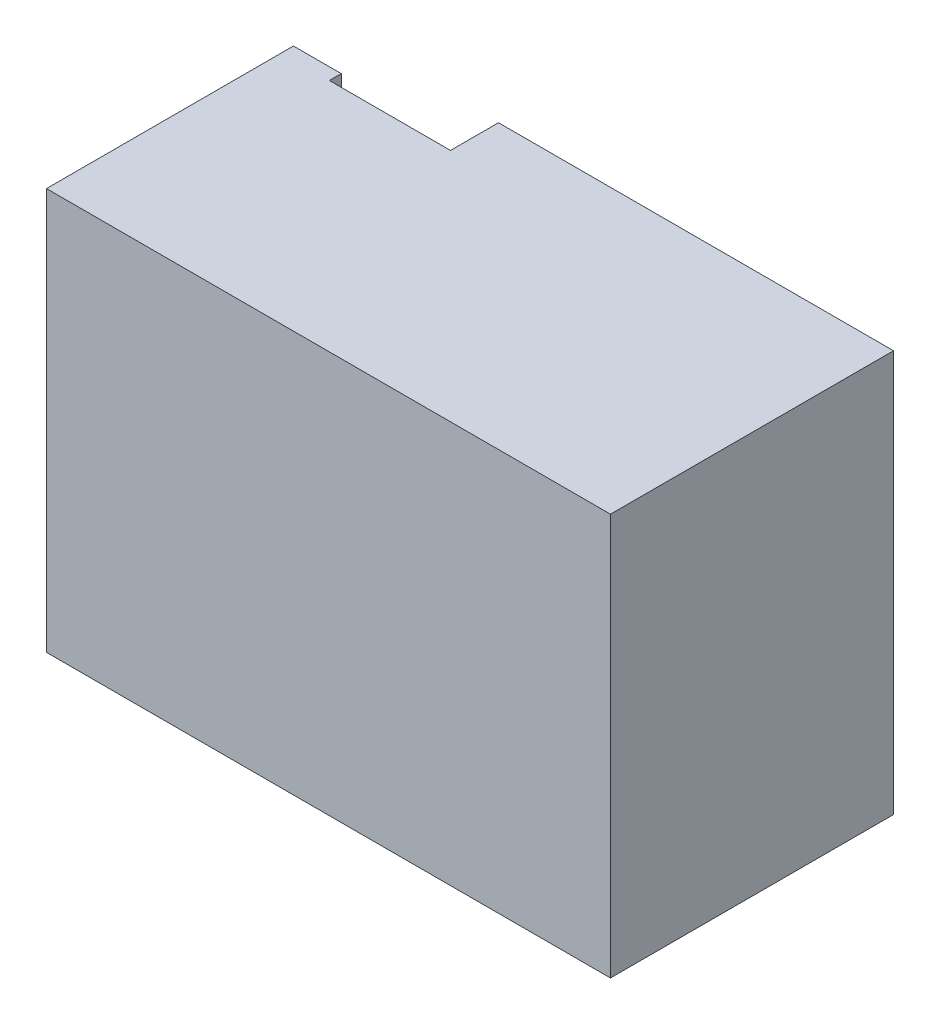
from build123d import *

# Parameters (mm, degrees)
SKETCH2_W           = 106.2
SKETCH2_H           = 108
BOSS_EXTRUDE1_DEPTH = 38.1
SKETCH3_W           = 25.19
SKETCH3_H           = 108
BOSS_EXTRUDE2_DEPTH = 45.43
SKETCH5_W           = 12.86
SKETCH5_H           = 108
BOSS_EXTRUDE4_DEPTH = 3.2
SKETCH6_W           = 151.63
SKETCH6_H           = 108
CUT_EXTRUDE1_DEPTH  = 21
SKETCH7_W           = 151.63
SKETCH7_H           = 108
BOSS_EXTRUDE5_DEPTH = 59


with BuildPart() as part:
    # Sketch2 → Boss-Extrude1 (new body)
    with BuildSketch(Plane.XY.offset(5.492308275)):
        with Locations((19.206268294, 5.678957245)):
            Rectangle(SKETCH2_W, SKETCH2_H)
    extrude(amount=BOSS_EXTRUDE1_DEPTH)

    # Sketch3 → Boss-Extrude2 (add)
    with BuildSketch(Plane.ZY.offset(33.893731706)):
        with Locations((30.997308275, 5.678957245)):
            Rectangle(SKETCH3_W, SKETCH3_H)
    extrude(amount=BOSS_EXTRUDE2_DEPTH)

    # Sketch5 → Boss-Extrude4 (add)
    with BuildSketch(Plane(origin=(0, 0, 18.402308275), x_dir=(-1, 0, 0), z_dir=(0, 0, -1))):
        with Locations((72.893731706, 5.678957245)):
            Rectangle(SKETCH5_W, SKETCH5_H)
    extrude(amount=BOSS_EXTRUDE4_DEPTH)

    # Sketch6 → Cut-Extrude1 (cut)
    with BuildSketch(Plane.XY.offset(43.592308275)):
        with Locations((-3.508731706, 5.678957245)):
            Rectangle(SKETCH6_W, SKETCH6_H)
    extrude(amount=-CUT_EXTRUDE1_DEPTH, mode=Mode.SUBTRACT)

    # Sketch7 → Boss-Extrude5 (add)
    with BuildSketch(Plane.XY.offset(22.592308275)):
        with Locations((-3.508731706, 5.678957245)):
            Rectangle(SKETCH7_W, SKETCH7_H)
    extrude(amount=BOSS_EXTRUDE5_DEPTH)


solid = part.part
